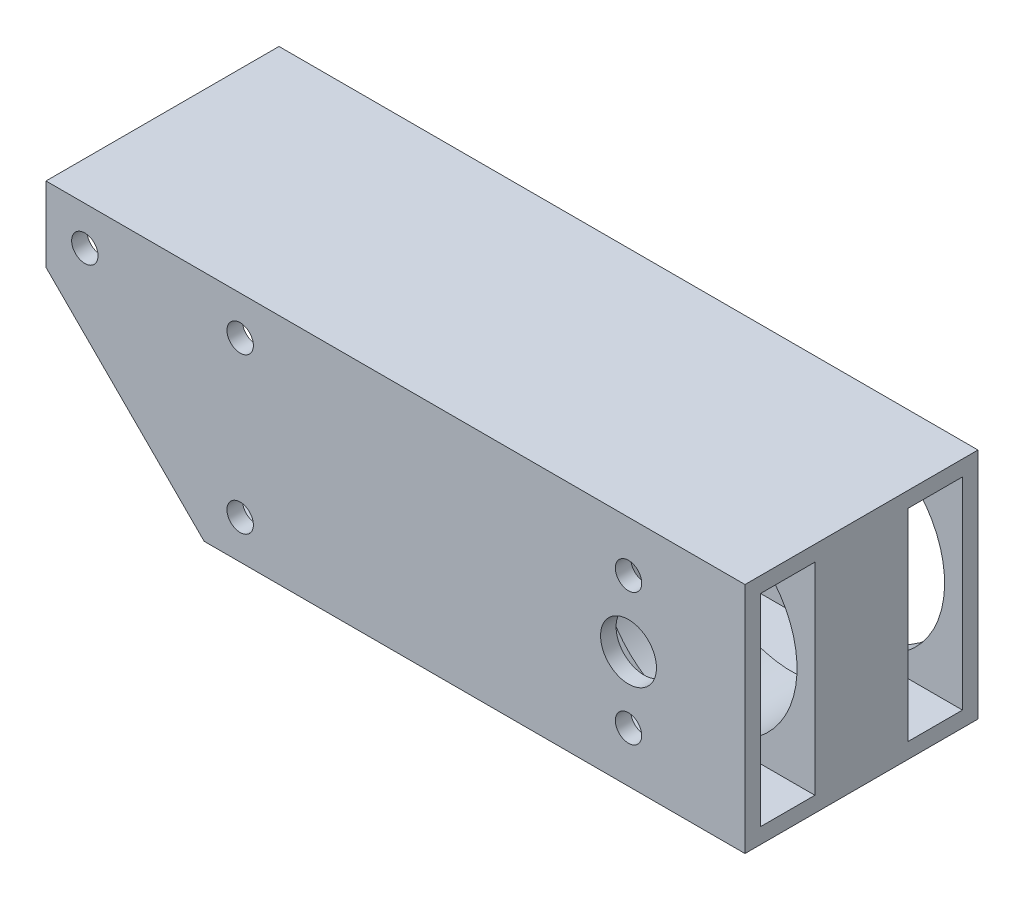
from build123d import *

# Parameters (mm, degrees)
SKETCH1_W               = 30
SKETCH1_H               = 30
SKETCH1_W_2             = 7
SKETCH1_H_2             = 26
BOSS_EXTRUDE3_DEPTH     = 90
SKETCH6_R               = 12.7
CUT_EXTRUDE5_DEPTH      = 23
SKETCH8_R               = 3.6
SKETCH8_R_2             = 1.7
CUT_EXTRUDE6_DEPTH      = 17
SKETCH9_W               = 12
SKETCH9_H               = 26
CUT_EXTRUDE7_DEPTH      = 59
M3_CLEARANCE_HOLE1_D    = 3.4
CUT_EXTRUDE8_DEPTH      = 28
CUT_EXTRUDE8_DEPTH_BACK = 26


with BuildPart() as part:
    # Sketch1 → Boss-Extrude3 (new body)
    with BuildSketch(Plane(origin=(0, 0, 0), x_dir=(0, 0, -1), z_dir=(1, 0, 0))):
        Rectangle(SKETCH1_W, SKETCH1_H)
        with Locations((-9.5, 0)):
            Rectangle(SKETCH1_W_2, SKETCH1_H_2, mode=Mode.SUBTRACT)
        with Locations((9.5, 0)):
            Rectangle(SKETCH1_W_2, SKETCH1_H_2, mode=Mode.SUBTRACT)
    extrude(amount=BOSS_EXTRUDE3_DEPTH)

    # Sketch6 → Cut-Extrude5 (cut)
    with BuildSketch(Plane(origin=(0, 0, -15), x_dir=(-1, 0, 0), z_dir=(0, 0, -1))):
        with Locations((-75, 0)):
            Circle(SKETCH6_R)
    extrude(amount=-CUT_EXTRUDE5_DEPTH, mode=Mode.SUBTRACT)

    # Sketch8 → Cut-Extrude6 (cut)
    with BuildSketch(Plane.XY.offset(15)):
        with Locations((75, 0)):
            Circle(SKETCH8_R)
        with Locations((75, 8.5)):
            Circle(SKETCH8_R_2)
        with Locations((75, -8.5)):
            Circle(SKETCH8_R_2)
    extrude(amount=-CUT_EXTRUDE6_DEPTH, mode=Mode.SUBTRACT)

    # Sketch9 → Cut-Extrude7 (cut)
    with BuildSketch(Plane.ZY):
        Rectangle(SKETCH9_W, SKETCH9_H)
    extrude(amount=-CUT_EXTRUDE7_DEPTH, mode=Mode.SUBTRACT)

    # M3 Clearance Hole1 (through all)
    with Locations(Plane.XY.offset(15)):
        with Locations((25, 10), (5, -10), (25, -10), (5, 10)):
            Hole(M3_CLEARANCE_HOLE1_D / 2)

    # Sketch13 → Cut-Extrude8 (cut, two sides: drawn at the far end of the back side and taken through both)
    with BuildSketch(Plane.XY.offset(-CUT_EXTRUDE8_DEPTH_BACK)):
        Polygon((0, -15), (20.364675298, -15), (0, 5.364675298), align=None)
    extrude(amount=CUT_EXTRUDE8_DEPTH + CUT_EXTRUDE8_DEPTH_BACK, mode=Mode.SUBTRACT)


solid = part.part
